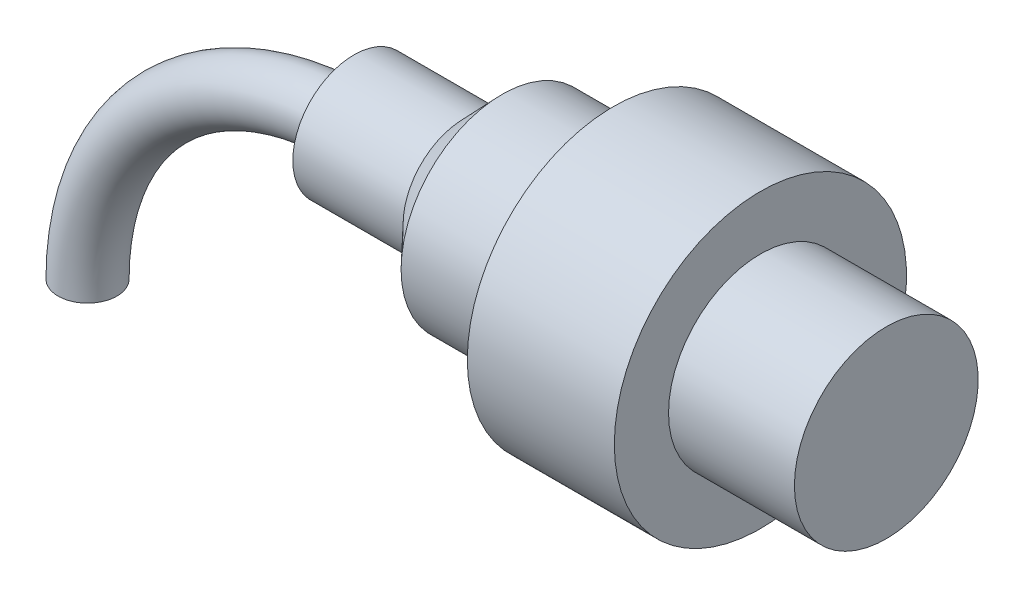
from build123d import *

# Parameters (mm, degrees)
SKETCH2_R   = 3.2
SKETCH4_W   = 12
SKETCH4_H   = 6.65
SKETCH4_W_2 = 13.7
SKETCH4_H_2 = 10


with BuildPart() as part:
    # Sweep1: sweep along a path in Sketch1
    with BuildLine(Plane.XY) as sweep1_path:
        ThreePointArc((0, 0), (8.491378029, 20.5), (28.991378029, 28.991378029))
    # Sketch2 → Sweep1 (sweep)
    with BuildSketch(Plane(origin=(0, 0, 0), x_dir=(1, 0, 0), z_dir=(0, 1, 0))):
        Circle(SKETCH2_R)
    sweep(path=sweep1_path.line)

    # Sketch4 → Revolve1 (revolve)
    with BuildSketch(Plane.XY, mode=Mode.PRIVATE) as revolve1_sk:
        with Locations((34.991378029, 32.316378029)):
            Rectangle(SKETCH4_W, SKETCH4_H)
        Polygon((55.123871223, 28.991378029), (40.991378029, 28.991378029), (40.991378029, 35.641378029), (45.123871223, 39.991378029), (55.123871223, 39.991378029), align=None)
        Polygon((73.231001973, 28.991378029), (55.123871223, 28.991378029), (55.123871223, 39.991378029), (57.231001973, 43.391378029), (57.231001973, 44.891378029), (73.231001973, 44.891378029), align=None)
        with Locations((80.081001973, 33.991378029)):
            Rectangle(SKETCH4_W_2, SKETCH4_H_2)
    revolve(revolve1_sk.sketch.rotate(Axis((28.991378029, 28.991378029, 0), (1, 0, 0)), 90), axis=Axis((28.991378029, 28.991378029, 0), (1, 0, 0)))  # turned: the seam where the file's is


solid = part.part
